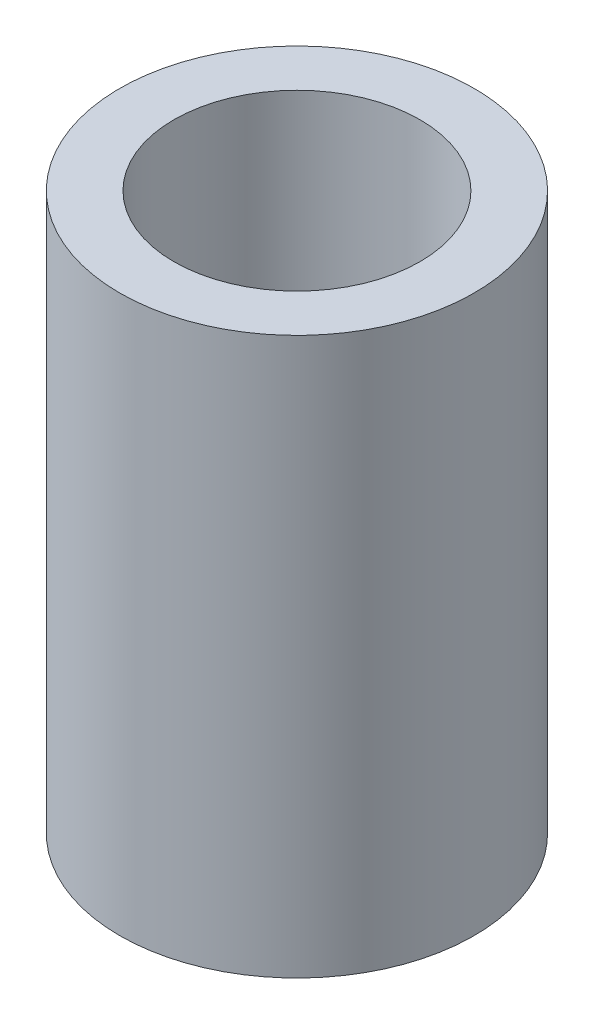
from build123d import *

# Parameters (mm, degrees)
SKETCH1_R           = 3.025
SKETCH1_R_2         = 2.1
BOSS_EXTRUDE1_DEPTH = 9.5


with BuildPart() as part:
    # Sketch1 → Boss-Extrude1 (new body)
    with BuildSketch(Plane(origin=(0, 0, 0), x_dir=(1, 0, 0), z_dir=(0, 1, 0))):
        Circle(SKETCH1_R)
        Circle(SKETCH1_R_2, mode=Mode.SUBTRACT)
    extrude(amount=BOSS_EXTRUDE1_DEPTH)


solid = part.part
